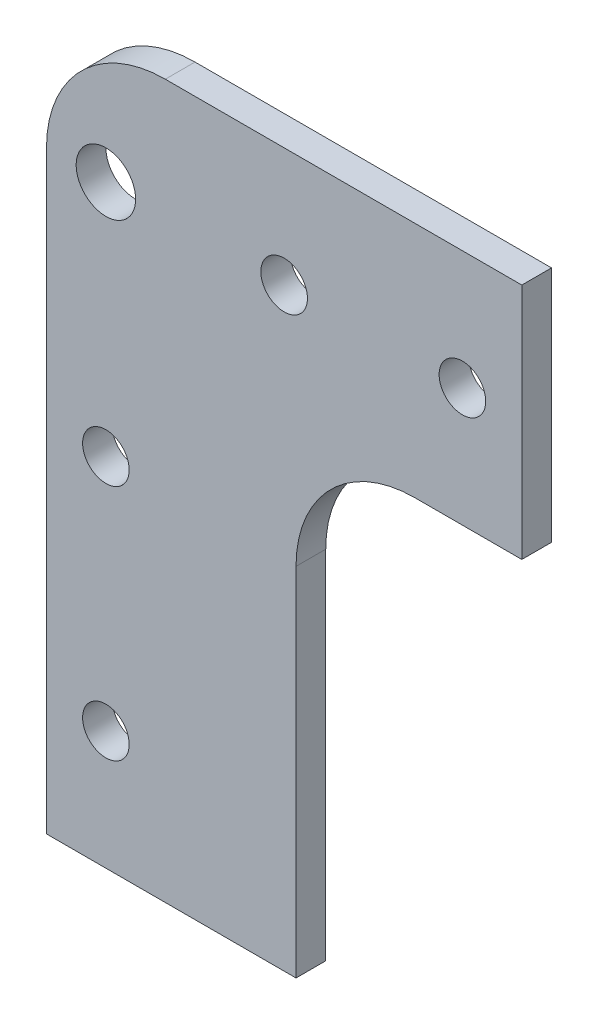
from build123d import *

# Parameters (mm, degrees)
SKETCH1_R           = 2.4892
SKETCH1_R_2         = 3.175
BOSS_EXTRUDE1_DEPTH = 3.175
FILLET1_R           = 12.7


with BuildPart() as part:
    # Sketch1 → Boss-Extrude1 (new body)
    with BuildSketch(Plane.XY):
        Polygon((0, 0), (50.8, 0), (50.8, -25.4), (26.67, -25.4), (26.67, -76.2), (0, -76.2), align=None)
        with Locations((44.45, -12.7)):
            Circle(SKETCH1_R, mode=Mode.SUBTRACT)
        with Locations((25.4, -12.7)):
            Circle(SKETCH1_R, mode=Mode.SUBTRACT)
        with Locations((6.35, -12.7)):
            Circle(SKETCH1_R_2, mode=Mode.SUBTRACT)
        with Locations((6.35, -38.1)):
            Circle(SKETCH1_R, mode=Mode.SUBTRACT)
        with Locations((6.35, -63.5)):
            Circle(SKETCH1_R, mode=Mode.SUBTRACT)
    extrude(amount=BOSS_EXTRUDE1_DEPTH)

    # Fillet1
    fillet1_edges = [part.edges().sort_by_distance(p)[0] for p in [
        (0, 0, 1.5875),
        (26.67, -25.4, 1.5875),
    ]]
    fillet(fillet1_edges, radius=FILLET1_R)


solid = part.part
